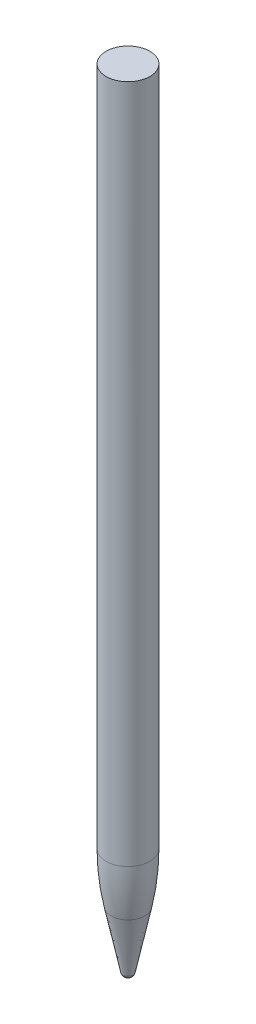
from build123d import *

# Parameters (mm, degrees)
FILLET1_R = 1
FILLET2_R = 50


with BuildPart() as part:
    # Sketch1 → Revolve1 (revolve)
    with BuildSketch(Plane.XY, mode=Mode.PRIVATE) as revolve1_sk:
        Polygon((0.875, 0.713567683), (4.425, 18), (4.425, 160.5), (0, 160.5), (0, 0.713567683), align=None)
    revolve(revolve1_sk.sketch.rotate(Axis((0, 160.5, 0), (0, -1, 0)), 90), axis=Axis((0, 160.5, 0), (0, -1, 0)))

    # Fillet1
    fillet1_edges = [part.edges().sort_by_distance(p)[0] for p in [
        (0, 0.713567683, -0.875),
    ]]
    fillet(fillet1_edges, radius=FILLET1_R)

    # Fillet2
    fillet2_edges = [part.edges().sort_by_distance(p)[0] for p in [
        (0, 18, -4.425),
    ]]
    fillet(fillet2_edges, radius=FILLET2_R)


solid = part.part
